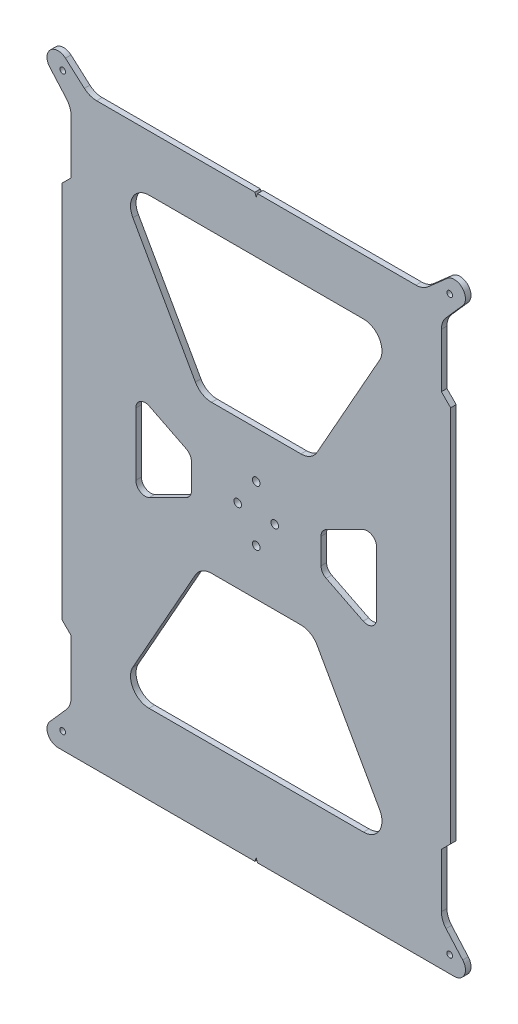
from build123d import *

# Parameters (mm, degrees)
MODEL_R                 = 1.55
MODEL_R_2               = 2.05
SALIENTE_EXTRUIR1_DEPTH = 3


with BuildPart() as part:
    # Model → Saliente-Extruir1 (new body)
    with BuildSketch(Plane.XY):
        with BuildLine():
            Line((-102.502115315, -142.835304077), (-111.498730811, -153.029934372))
            ThreePointArc((-111.498730811, -153.029934372), (-112.469021565, -159.467752645), (-107, -163))
            Line((-107, -163), (-0.700702433, -163))
            Line((-0.700702433, -163), (0, -160.996661892))
            Line((0, -160.996661892), (0.699463472, -163))
            Line((0.699463472, -163), (107, -163))
            ThreePointArc((107, -163), (112.469021565, -159.467752645), (111.498730811, -153.029934372))
            Line((111.498730811, -153.029934372), (102.502115315, -142.835304077))
            ThreePointArc((102.502115315, -142.835304077), (100.646421892, -139.755557374), (100, -136.21852803))
            Line((100, -136.21852803), (100, -107))
            Line((100, -107), (105, -102))
            Line((105, -102), (105, 102))
            Line((105, 102), (100, 107))
            Line((100, 107), (100, 136.21852803))
            ThreePointArc((100, 136.21852803), (100.646421892, 139.755557374), (102.502115315, 142.835304077))
            Line((102.502115315, 142.835304077), (111.498730811, 153.029934372))
            ThreePointArc((111.498730811, 153.029934372), (111.242640687, 161.242640687), (103.029934372, 161.498730811))
            Line((103.029934372, 161.498730811), (92.835304077, 152.502115315))
            ThreePointArc((92.835304077, 152.502115315), (89.755557374, 150.646421892), (86.21852803, 150))
            Line((86.21852803, 150), (0.701283747, 150))
            Line((0.701283747, 150), (0, 148))
            Line((0, 148), (-0.697387345, 150))
            Line((-0.697387345, 150), (-86.21852803, 150))
            ThreePointArc((-86.21852803, 150), (-89.755557374, 150.646421892), (-92.835304077, 152.502115315))
            Line((-92.835304077, 152.502115315), (-103.029934372, 161.498730811))
            ThreePointArc((-103.029934372, 161.498730811), (-111.242640687, 161.242640687), (-111.498730811, 153.029934372))
            Line((-111.498730811, 153.029934372), (-102.502115315, 142.835304077))
            ThreePointArc((-102.502115315, 142.835304077), (-100.646421892, 139.755557374), (-100, 136.21852803))
            Line((-100, 136.21852803), (-100, 107))
            Line((-100, 107), (-105, 102))
            Line((-105, 102), (-105, -102))
            Line((-105, -102), (-100, -107))
            Line((-100, -107), (-100, -136.21852803))
            ThreePointArc((-100, -136.21852803), (-100.646421892, -139.755557374), (-102.502115315, -142.835304077))
        make_face()
        with Locations((-104.5, -154)):
            Circle(MODEL_R, mode=Mode.SUBTRACT)
        with Locations((104.5, -154)):
            Circle(MODEL_R, mode=Mode.SUBTRACT)
        with Locations((-10, 0)):
            Circle(MODEL_R_2, mode=Mode.SUBTRACT)
        with Locations((0, -15)):
            Circle(MODEL_R_2, mode=Mode.SUBTRACT)
        with Locations((10, 0)):
            Circle(MODEL_R_2, mode=Mode.SUBTRACT)
        with Locations((0, 15)):
            Circle(MODEL_R_2, mode=Mode.SUBTRACT)
        with Locations((104.5, 155)):
            Circle(MODEL_R, mode=Mode.SUBTRACT)
        with Locations((-104.5, 155)):
            Circle(MODEL_R, mode=Mode.SUBTRACT)
        with BuildLine():
            Line((24.151525156, -40), (-24.151525156, -40))
            ThreePointArc((-24.151525156, -40), (-29.19998413, -41.367905122), (-32.867280527, -45.097387604))
            Line((-32.867280527, -45.097387604), (-66.617280527, -105.097387604))
            ThreePointArc((-66.617280527, -105.097387604), (-66.533620034, -115.048458975), (-57.901525156, -120))
            Line((-57.901525156, -120), (57.901525156, -120))
            ThreePointArc((57.901525156, -120), (66.533620034, -115.048458975), (66.617280527, -105.097387604))
            Line((66.617280527, -105.097387604), (32.867280527, -45.097387604))
            ThreePointArc((32.867280527, -45.097387604), (29.19998413, -41.367905122), (24.151525156, -40))
        make_face(mode=Mode.SUBTRACT)
        with BuildLine():
            Line((32.867280527, 45.097387604), (66.617280527, 105.097387604))
            ThreePointArc((66.617280527, 105.097387604), (66.533620034, 115.048458975), (57.901525156, 120))
            Line((57.901525156, 120), (-57.901525156, 120))
            ThreePointArc((-57.901525156, 120), (-66.533620034, 115.048458975), (-66.617280527, 105.097387604))
            Line((-66.617280527, 105.097387604), (-32.867280527, 45.097387604))
            ThreePointArc((-32.867280527, 45.097387604), (-29.19998413, 41.367905122), (-24.151525156, 40))
            Line((-24.151525156, 40), (24.151525156, 40))
            ThreePointArc((24.151525156, 40), (29.19998413, 41.367905122), (32.867280527, 45.097387604))
        make_face(mode=Mode.SUBTRACT)
        with BuildLine():
            Line((-37.763932023, 11.381966011), (-57.763932023, 21.381966011))
            ThreePointArc((-57.763932023, 21.381966011), (-62.628655561, 21.163084098), (-65, 16.909830056))
            Line((-65, 16.909830056), (-65, -16.909830056))
            ThreePointArc((-65, -16.909830056), (-62.628655561, -21.163084098), (-57.763932023, -21.381966011))
            Line((-57.763932023, -21.381966011), (-37.763932023, -11.381966011))
            ThreePointArc((-37.763932023, -11.381966011), (-35.746745958, -9.538485617), (-35, -6.909830056))
            Line((-35, -6.909830056), (-35, 6.909830056))
            ThreePointArc((-35, 6.909830056), (-35.746745958, 9.538485617), (-37.763932023, 11.381966011))
        make_face(mode=Mode.SUBTRACT)
        with BuildLine():
            Line((37.763932023, -11.381966011), (57.763932023, -21.381966011))
            ThreePointArc((57.763932023, -21.381966011), (62.628655561, -21.163084098), (65, -16.909830056))
            Line((65, -16.909830056), (65, 16.909830056))
            ThreePointArc((65, 16.909830056), (62.628655561, 21.163084098), (57.763932023, 21.381966011))
            Line((57.763932023, 21.381966011), (37.763932023, 11.381966011))
            ThreePointArc((37.763932023, 11.381966011), (35.746745958, 9.538485617), (35, 6.909830056))
            Line((35, 6.909830056), (35, -6.909830056))
            ThreePointArc((35, -6.909830056), (35.746745958, -9.538485617), (37.763932023, -11.381966011))
        make_face(mode=Mode.SUBTRACT)
    extrude(amount=SALIENTE_EXTRUIR1_DEPTH)


solid = part.part
